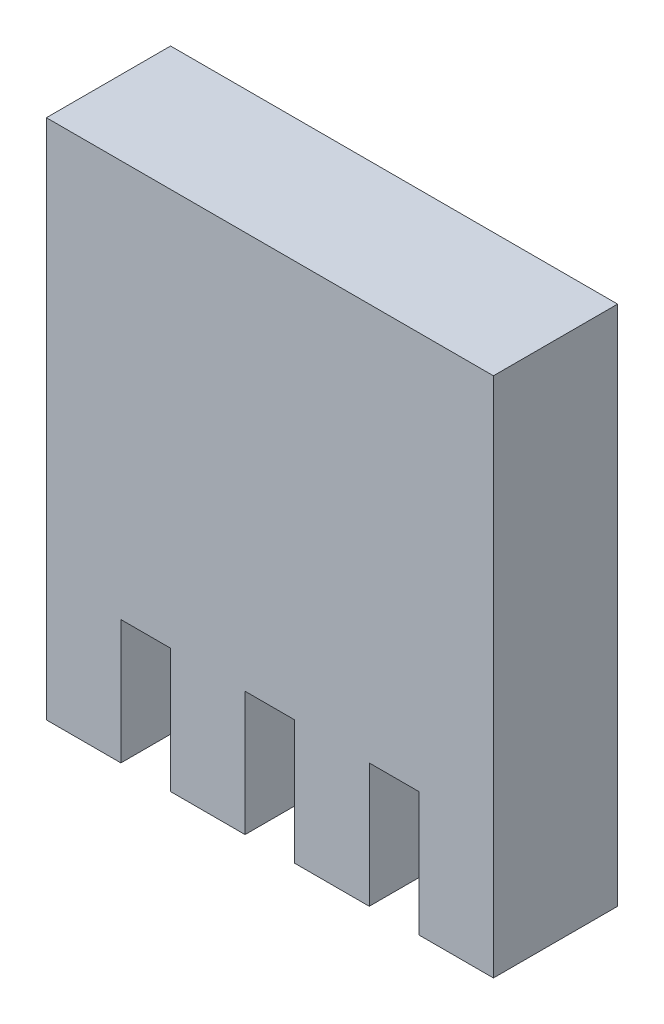
from build123d import *

# Parameters (mm, degrees)
BOSS_EXTRU_2_DEPTH = 5


with BuildPart() as part:
    # Esquisse1 → Boss.-Extru.2 (new body)
    with BuildSketch(Plane.XY):
        Polygon((0, 16), (0, -5), (3, -5), (3, 0), (5, 0), (5, -5), (8, -5), (8, 0), (10, 0), (10, -5), (13, -5), (13, 0), (15, 0), (15, -5), (18, -5), (18, 16), align=None)
    extrude(amount=BOSS_EXTRU_2_DEPTH)


solid = part.part
